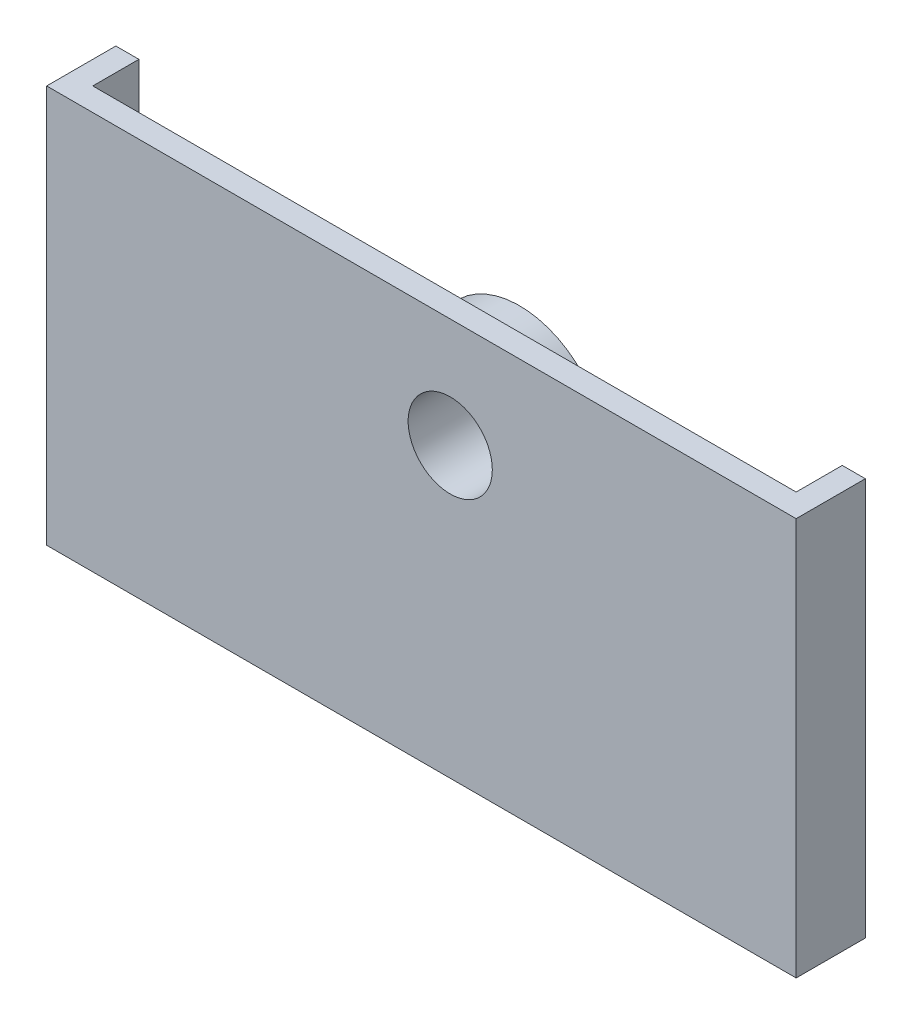
from build123d import *

# Parameters (mm, degrees)
SKETCH_2_R          = 7.5
SKETCH_2_R_2        = 3.65
EXTRUDE_1_DEPTH     = 4
SKETCH_3_W          = 65
SKETCH_3_H          = 34.5
SKETCH_3_R          = 3.65
EXTRUDE_2_DEPTH     = 2
EXTRUDE_3_DEPTH     = 4
SKETCH_5_W          = 10
SKETCH_5_H          = 2
CUT_EXTRUDE_1_DEPTH = 3.7
FILLET_1_R          = 1.5
SKETCH_6_W          = 2
SKETCH_6_H          = 10
CUT_EXTRUDE_2_DEPTH = 5
SKETCH_7_W          = 1
SKETCH_7_H          = 10
CUT_EXTRUDE_3_DEPTH = 5.5


with BuildPart() as part:
    # 草图2 → 凸台-拉伸1 (new body)
    with BuildSketch(Plane.XY):
        Circle(SKETCH_2_R)
        Circle(SKETCH_2_R_2, mode=Mode.SUBTRACT)
    extrude(amount=EXTRUDE_1_DEPTH)

    # 草图3 → 凸台-拉伸2 (add)
    with BuildSketch(Plane.XY.offset(4)):
        with Locations((-2.5, -7.75)):
            Rectangle(SKETCH_3_W, SKETCH_3_H)
        Circle(SKETCH_3_R, mode=Mode.SUBTRACT)
    extrude(amount=EXTRUDE_2_DEPTH)

    # 草图4 → 凸台-拉伸3 (add)
    with BuildSketch(Plane(origin=(0, 0, 4), x_dir=(-1, 0, 0), z_dir=(0, 0, -1))):
        Polygon((-28, 7.5), (-28, -23), (33, -23), (33, 7.5), (33, 9.5), (35, 9.5), (35, -25), (-30, -25), (-30, 9.5), (-28, 9.5), align=None)
    extrude(amount=EXTRUDE_3_DEPTH)

    # 草图5 → 切除-拉伸1 (cut)
    with BuildSketch(Plane(origin=(0, 0, 0), x_dir=(-1, 0, 0), z_dir=(0, 0, -1))):
        with Locations((0, -24)):
            Rectangle(SKETCH_5_W, SKETCH_5_H)
    extrude(amount=-CUT_EXTRUDE_1_DEPTH, mode=Mode.SUBTRACT)

    # 圆角1
    fillet_1_edges = [part.edges().sort_by_distance(p)[0] for p in [
        (5, -24, 3.7),
        (-5, -24, 3.7),
    ]]
    fillet(fillet_1_edges, radius=FILLET_1_R)

    # 草图6 → 切除-拉伸2 (cut)
    with BuildSketch(Plane(origin=(0, 0, 0), x_dir=(-1, 0, 0), z_dir=(0, 0, -1))):
        with Locations((34, -2)):
            Rectangle(SKETCH_6_W, SKETCH_6_H)
    extrude(amount=-CUT_EXTRUDE_2_DEPTH, mode=Mode.SUBTRACT)

    # 草图7 → 切除-拉伸3 (cut)
    with BuildSketch(Plane.ZY.offset(33)):
        with Locations((4.5, -2)):
            Rectangle(SKETCH_7_W, SKETCH_7_H)
    extrude(amount=-CUT_EXTRUDE_3_DEPTH, mode=Mode.SUBTRACT)


solid = part.part
